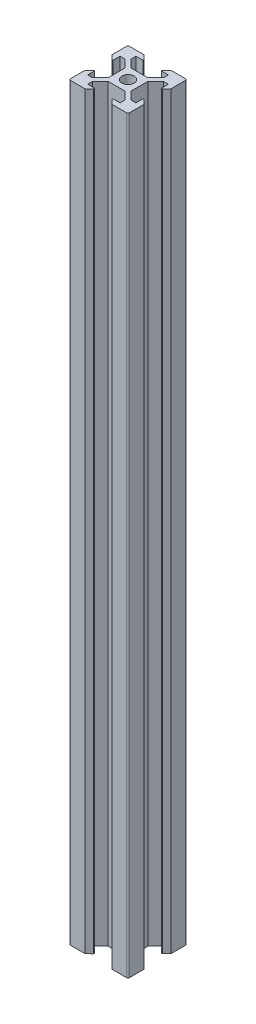
from build123d import *

# Parameters (mm, degrees)
SKETCH2_R              = 2.074585303
VSLOT2020_2020_5_DEPTH = 254


with BuildPart() as part:
    # Sketch2 → Vslot2020 2020(5) (new body)
    with BuildSketch(Plane.ZX):
        with BuildLine():
            Line((13.9, 7.149086807), (13.9, 12.844511469))
            Line((13.9, 12.844511469), (16.558493656, 15.492177728))
            Line((16.558493656, 15.492177728), (16.550703242, 15.5))
            Line((16.550703242, 15.5), (18.2, 15.5))
            Line((18.2, 15.5), (18.2, 13.12))
            Line((18.2, 13.12), (18.534428266, 13.12))
            Line((18.534428266, 13.12), (20, 14.58))
            Line((20, 14.58), (20, 19.5))
            ThreePointArc((20, 19.5), (19.853553391, 19.853553391), (19.5, 20))
            Line((19.5, 20), (14.575, 20))
            Line((14.575, 20), (13.12, 18.545))
            Line((13.12, 18.545), (13.12, 18.2))
            Line((13.12, 18.2), (15.5, 18.2))
            Line((15.5, 18.2), (15.5, 16.555))
            Line((15.5, 16.555), (12.834142613, 13.9))
            Line((12.834142613, 13.9), (7.155, 13.9))
            Line((7.155, 13.9), (4.5, 16.555))
            Line((4.5, 16.555), (4.5, 18.2))
            Line((4.5, 18.2), (6.875, 18.2))
            Line((6.875, 18.2), (6.875, 18.545))
            Line((6.875, 18.545), (5.42, 20))
            Line((5.42, 20), (0.5, 20))
            ThreePointArc((0.5, 20), (0.146446609, 19.853553391), (0, 19.5))
            Line((0, 19.5), (0, 14.58))
            Line((0, 14.58), (1.46, 13.12))
            Line((1.46, 13.12), (1.8, 13.12))
            Line((1.8, 13.12), (1.8, 15.5))
            Line((1.8, 15.5), (3.445, 15.5))
            Line((3.445, 15.5), (3.439339828, 15.494339828))
            Line((3.439339828, 15.494339828), (6.094339828, 12.839339828))
            Line((6.094339828, 12.839339828), (6.1, 12.845))
            Line((6.1, 12.845), (6.1, 7.149086807))
            Line((6.1, 7.149086807), (3.439339828, 4.5))
            Line((3.439339828, 4.5), (1.8, 4.5))
            Line((1.8, 4.5), (1.8, 6.88))
            Line((1.8, 6.88), (1.46, 6.88))
            Line((1.46, 6.88), (0, 5.42))
            Line((0, 5.42), (0, 0.5))
            ThreePointArc((0, 0.5), (0.146446609, 0.146446609), (0.5, 0))
            Line((0.5, 0), (5.42, 0))
            Line((5.42, 0), (6.875, 1.455))
            Line((6.875, 1.455), (6.875, 1.8))
            Line((6.875, 1.8), (4.5, 1.8))
            Line((4.5, 1.8), (4.5, 3.4393348))
            Line((4.5, 3.4393348), (7.158345795, 6.086117297))
            Line((7.158345795, 6.086117297), (7.144523479, 6.1))
            Line((7.144523479, 6.1), (12.854625295, 6.1))
            Line((12.854625295, 6.1), (12.841221344, 6.086548451))
            Line((12.841221344, 6.086548451), (15.499715, 3.437461644))
            Line((15.499715, 3.437461644), (15.5, 1.8))
            Line((15.5, 1.8), (13.12, 1.8))
            Line((13.12, 1.8), (13.12, 1.455))
            Line((13.12, 1.455), (14.575, 0))
            Line((14.575, 0), (19.5, 0))
            ThreePointArc((19.5, 0), (19.853553391, 0.146446609), (20, 0.5))
            Line((20, 0.5), (20, 5.42))
            Line((20, 5.42), (18.606904708, 6.88))
            Line((18.606904708, 6.88), (18.2, 6.88))
            Line((18.2, 6.88), (18.2, 4.5))
            Line((18.2, 4.5), (16.558493656, 4.5))
            Line((16.558493656, 4.5), (13.9, 7.149086807))
        make_face()
        with Locations((10, 10)):
            Circle(SKETCH2_R, mode=Mode.SUBTRACT)
    extrude(amount=VSLOT2020_2020_5_DEPTH)


solid = part.part
